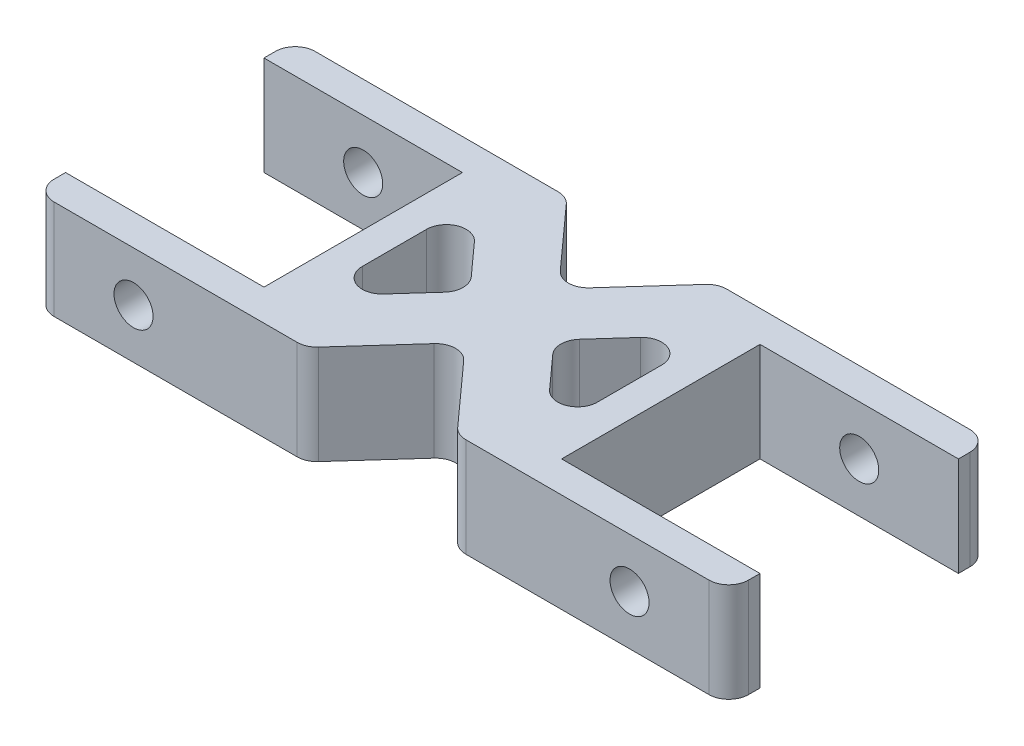
from build123d import *

# Parameters (mm, degrees)
BOSS_EXTRUDE1_DEPTH     = 12.7
FILLET1_R               = 2.54
SKETCH3_R               = 2.5
CUT_EXTRUDE1_DEPTH      = 30.4
CUT_EXTRUDE1_DEPTH_BACK = 5


with BuildPart() as part:
    # Sketch1 → Boss-Extrude1 (new body)
    with BuildSketch(Plane(origin=(0, 0, 0), x_dir=(1, 0, 0), z_dir=(0, 1, 0))):
        Polygon((-19.05, -12.7), (-19.05, 12.7), (-44.45, 12.7), (-44.45, 16.7), (-9.665344582, 16.7), (0, 5.974999699), (9.665344582, 16.7), (44.45, 16.7), (44.45, 12.7), (19.05, 12.7), (19.05, -12.7), (44.45, -12.7), (44.45, -16.7), (9.665344582, -16.7), (0, -5.974999699), (-9.665344582, -16.7), (-44.45, -16.7), (-44.45, -12.7), align=None)
        Polygon((-15.05, -10.725000301), (-15.05, 10.725000301), (-5.384655418, 0), align=None, mode=Mode.SUBTRACT)
        Polygon((15.05, -10.725000301), (15.05, 10.725000301), (5.384655418, 0), align=None, mode=Mode.SUBTRACT)
    extrude(amount=BOSS_EXTRUDE1_DEPTH)

    # Fillet1
    fillet1_edges = [part.edges().sort_by_distance(p)[0] for p in [
        (-44.45, 6.35, -16.7),
        (-9.665344582, 6.35, -16.7),
        (0, 6.35, -5.974999699),
        (9.665344582, 6.35, -16.7),
        (44.45, 6.35, -16.7),
        (44.45, 6.35, 16.7),
        (9.665344582, 6.35, 16.7),
        (0, 6.35, 5.974999699),
        (-9.665344582, 6.35, 16.7),
        (-44.45, 6.35, 16.7),
        (-15.05, 6.35, 10.725000301),
        (-5.384655418, 6.35, 0),
        (-15.05, 6.35, -10.725000301),
        (5.384655418, 6.35, 0),
        (15.05, 6.35, 10.725000301),
        (15.05, 6.35, -10.725000301),
    ]]
    fillet(fillet1_edges, radius=FILLET1_R)

    # Sketch3 → Cut-Extrude1 (cut, two sides)
    with BuildSketch(Plane.XY.offset(-12.7)) as cut_extrude1_sk:
        with Locations((-31.75, 6.35)):
            Circle(SKETCH3_R)
        with Locations((31.75, 6.35)):
            Circle(SKETCH3_R)
    extrude(amount=CUT_EXTRUDE1_DEPTH, mode=Mode.SUBTRACT)
    extrude(cut_extrude1_sk.sketch, amount=-CUT_EXTRUDE1_DEPTH_BACK, mode=Mode.SUBTRACT)


solid = part.part
